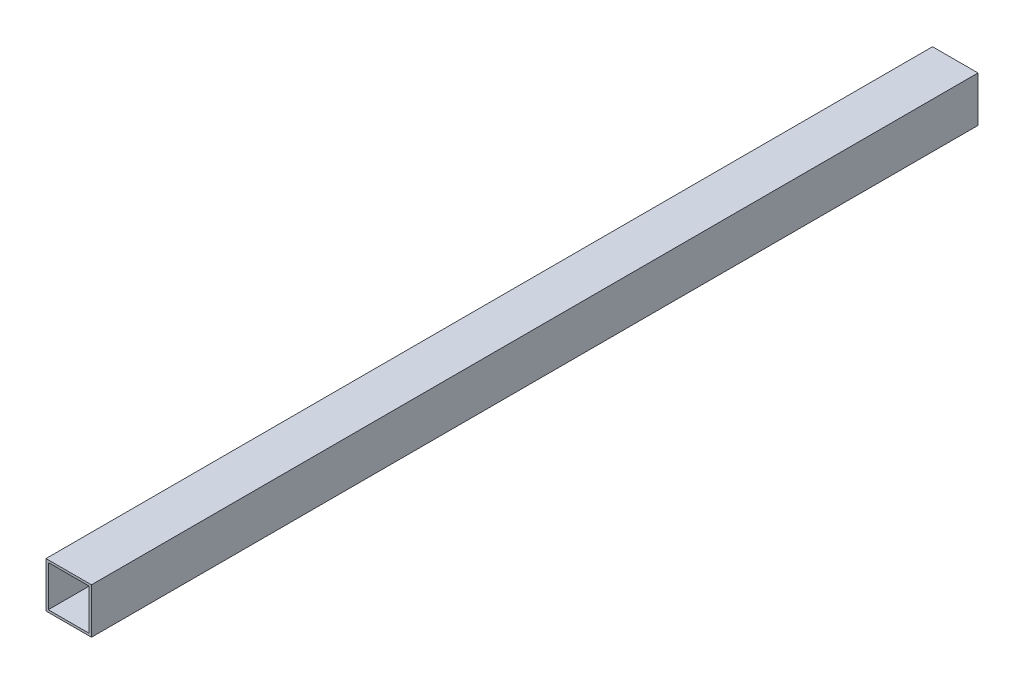
from build123d import *

# Parameters (mm, degrees)
SKETCH1_W           = 20
SKETCH1_H           = 20
SKETCH1_W_2         = 18
SKETCH1_H_2         = 18
BOSS_EXTRUDE1_DEPTH = 390


with BuildPart() as part:
    # Sketch1 → Boss-Extrude1 (new body)
    with BuildSketch(Plane.XY):
        with Locations((10, -10)):
            Rectangle(SKETCH1_W, SKETCH1_H)
        with Locations((10, -10)):
            Rectangle(SKETCH1_W_2, SKETCH1_H_2, mode=Mode.SUBTRACT)
    extrude(amount=BOSS_EXTRUDE1_DEPTH)


solid = part.part
